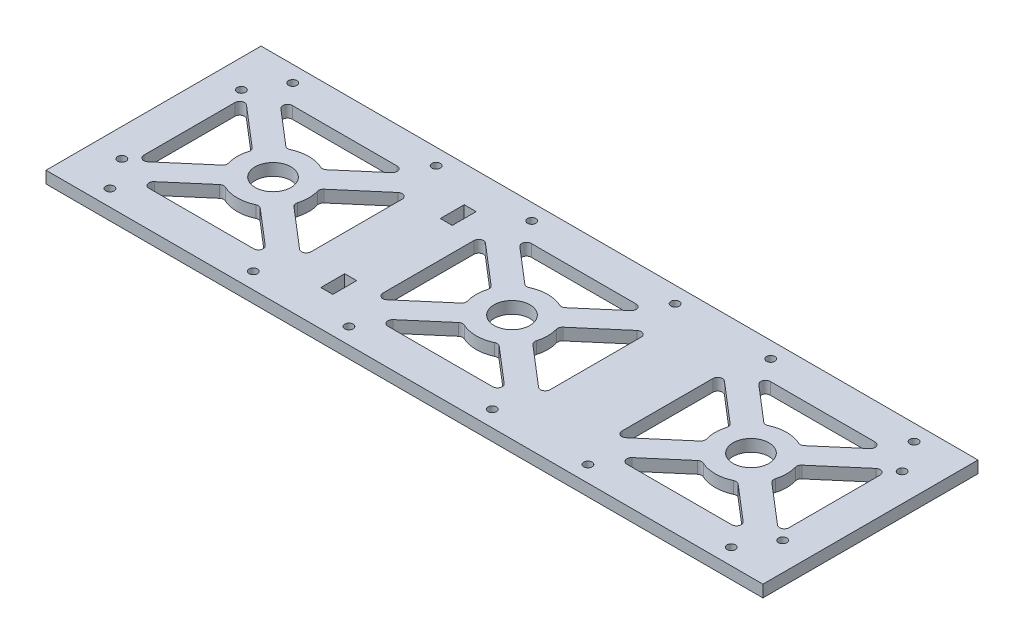
from build123d import *

# Parameters (mm, degrees)
SKETCH1_R           = 7.5
SKETCH1_R_2         = 1.75
SKETCH1_W           = 5
SKETCH1_H           = 10
BOSS_EXTRUDE2_DEPTH = 5


with BuildPart() as part:
    # Sketch1 → Boss-Extrude2 (new body)
    with BuildSketch(Plane(origin=(0, 0, 0), x_dir=(1, 0, 0), z_dir=(0, 1, 0))):
        Polygon((-50, 45), (150, 45), (150, -45), (-50, -45), (-150, -45), (-150, 45), align=None)
        Circle(SKETCH1_R, mode=Mode.SUBTRACT)
        with Locations((100, 0)):
            Circle(SKETCH1_R, mode=Mode.SUBTRACT)
        with Locations((-100, 0)):
            Circle(SKETCH1_R, mode=Mode.SUBTRACT)
        with Locations((-138.25, 25)):
            Circle(SKETCH1_R_2, mode=Mode.SUBTRACT)
        with Locations((-130, 38.25)):
            Circle(SKETCH1_R_2, mode=Mode.SUBTRACT)
        with Locations((-138.25, -25)):
            Circle(SKETCH1_R_2, mode=Mode.SUBTRACT)
        with Locations((-70, 38.25)):
            Circle(SKETCH1_R_2, mode=Mode.SUBTRACT)
        with Locations((-30, 38.25)):
            Circle(SKETCH1_R_2, mode=Mode.SUBTRACT)
        with Locations((30, 38.25)):
            Circle(SKETCH1_R_2, mode=Mode.SUBTRACT)
        with Locations((70, 38.25)):
            Circle(SKETCH1_R_2, mode=Mode.SUBTRACT)
        with Locations((130, 38.25)):
            Circle(SKETCH1_R_2, mode=Mode.SUBTRACT)
        with Locations((-130, -38.25)):
            Circle(SKETCH1_R_2, mode=Mode.SUBTRACT)
        with Locations((-70, -38.25)):
            Circle(SKETCH1_R_2, mode=Mode.SUBTRACT)
        with Locations((-30, -38.25)):
            Circle(SKETCH1_R_2, mode=Mode.SUBTRACT)
        with Locations((30, -38.25)):
            Circle(SKETCH1_R_2, mode=Mode.SUBTRACT)
        with Locations((70, -38.25)):
            Circle(SKETCH1_R_2, mode=Mode.SUBTRACT)
        with Locations((130, -38.25)):
            Circle(SKETCH1_R_2, mode=Mode.SUBTRACT)
        with Locations((138.25, -25)):
            Circle(SKETCH1_R_2, mode=Mode.SUBTRACT)
        with Locations((138.25, 25)):
            Circle(SKETCH1_R_2, mode=Mode.SUBTRACT)
        with BuildLine():
            Line((-21.910531466, 30), (21.910531466, 30))
            ThreePointArc((21.910531466, 30), (23.786301496, 28.693892495), (23.212114213, 26.481486795))
            Line((23.212114213, 26.481486795), (8.508395839, 13.878299617))
            ThreePointArc((8.508395839, 13.878299617), (7.476831919, 13.41512419), (6.358952728, 13.585423078))
            ThreePointArc((6.358952728, 13.585423078), (0, 15), (-6.358952728, 13.585423078))
            ThreePointArc((-6.358952728, 13.585423078), (-7.476831919, 13.41512419), (-8.508395839, 13.878299617))
            Line((-8.508395839, 13.878299617), (-23.212114213, 26.481486795))
            ThreePointArc((-23.212114213, 26.481486795), (-23.786301496, 28.693892495), (-21.910531466, 30))
        make_face(mode=Mode.SUBTRACT)
        with BuildLine():
            Line((-35, 19.066169828), (-35, -19.066169828))
            ThreePointArc((-35, -19.066169828), (-33.835713619, -20.883195625), (-31.698417253, -20.584683033))
            Line((-31.698417253, -20.584683033), (-15.016309573, -6.285733593))
            ThreePointArc((-15.016309573, -6.285733593), (-14.400814669, -5.337144314), (-14.398140282, -4.206370931))
            ThreePointArc((-14.398140282, -4.206370931), (-15, 0), (-14.398140282, 4.206370931))
            ThreePointArc((-14.398140282, 4.206370931), (-14.400814669, 5.337144314), (-15.016309573, 6.285733593))
            Line((-15.016309573, 6.285733593), (-31.698417253, 20.584683033))
            ThreePointArc((-31.698417253, 20.584683033), (-33.835713619, 20.883195625), (-35, 19.066169828))
        make_face(mode=Mode.SUBTRACT)
        with BuildLine():
            Line((-21.910531466, -30), (21.910531466, -30))
            ThreePointArc((21.910531466, -30), (23.786301496, -28.693892495), (23.212114213, -26.481486795))
            Line((23.212114213, -26.481486795), (8.508395839, -13.878299617))
            ThreePointArc((8.508395839, -13.878299617), (7.476831919, -13.41512419), (6.358952728, -13.585423078))
            ThreePointArc((6.358952728, -13.585423078), (0, -15), (-6.358952728, -13.585423078))
            ThreePointArc((-6.358952728, -13.585423078), (-7.476831919, -13.41512419), (-8.508395839, -13.878299617))
            Line((-8.508395839, -13.878299617), (-23.212114213, -26.481486795))
            ThreePointArc((-23.212114213, -26.481486795), (-23.786301496, -28.693892495), (-21.910531466, -30))
        make_face(mode=Mode.SUBTRACT)
        with BuildLine():
            Line((35, 19.066169828), (35, -19.066169828))
            ThreePointArc((35, -19.066169828), (33.835713619, -20.883195625), (31.698417253, -20.584683033))
            Line((31.698417253, -20.584683033), (15.016309573, -6.285733593))
            ThreePointArc((15.016309573, -6.285733593), (14.400814669, -5.337144314), (14.398140282, -4.206370931))
            ThreePointArc((14.398140282, -4.206370931), (15, 0), (14.398140282, 4.206370931))
            ThreePointArc((14.398140282, 4.206370931), (14.400814669, 5.337144314), (15.016309573, 6.285733593))
            Line((15.016309573, 6.285733593), (31.698417253, 20.584683033))
            ThreePointArc((31.698417253, 20.584683033), (33.835713619, 20.883195625), (35, 19.066169828))
        make_face(mode=Mode.SUBTRACT)
        with BuildLine():
            Line((131.698417253, -20.584683033), (115.016309573, -6.285733593))
            ThreePointArc((115.016309573, -6.285733593), (114.400814669, -5.337144314), (114.398140282, -4.206370931))
            ThreePointArc((114.398140282, -4.206370931), (115, 0), (114.398140282, 4.206370931))
            ThreePointArc((114.398140282, 4.206370931), (114.400814669, 5.337144314), (115.016309573, 6.285733593))
            Line((115.016309573, 6.285733593), (131.698417253, 20.584683033))
            ThreePointArc((131.698417253, 20.584683033), (133.835713619, 20.883195625), (135, 19.066169828))
            Line((135, 19.066169828), (135, -19.066169828))
            ThreePointArc((135, -19.066169828), (133.835713619, -20.883195625), (131.698417253, -20.584683033))
        make_face(mode=Mode.SUBTRACT)
        with BuildLine():
            Line((123.212114213, -26.481486795), (108.508395839, -13.878299617))
            ThreePointArc((108.508395839, -13.878299617), (107.476831919, -13.41512419), (106.358952728, -13.585423078))
            ThreePointArc((106.358952728, -13.585423078), (100, -15), (93.641047272, -13.585423078))
            ThreePointArc((93.641047272, -13.585423078), (92.523168081, -13.41512419), (91.491604161, -13.878299617))
            Line((91.491604161, -13.878299617), (76.787885787, -26.481486795))
            ThreePointArc((76.787885787, -26.481486795), (76.213698504, -28.693892495), (78.089468534, -30))
            Line((78.089468534, -30), (121.910531466, -30))
            ThreePointArc((121.910531466, -30), (123.786301496, -28.693892495), (123.212114213, -26.481486795))
        make_face(mode=Mode.SUBTRACT)
        with BuildLine():
            Line((68.301582747, -20.584683033), (84.983690427, -6.285733593))
            ThreePointArc((84.983690427, -6.285733593), (85.599185331, -5.337144314), (85.601859718, -4.206370931))
            ThreePointArc((85.601859718, -4.206370931), (85, 0), (85.601859718, 4.206370931))
            ThreePointArc((85.601859718, 4.206370931), (85.599185331, 5.337144314), (84.983690427, 6.285733593))
            Line((84.983690427, 6.285733593), (68.301582747, 20.584683033))
            ThreePointArc((68.301582747, 20.584683033), (66.164286381, 20.883195625), (65, 19.066169828))
            Line((65, 19.066169828), (65, -19.066169828))
            ThreePointArc((65, -19.066169828), (66.164286381, -20.883195625), (68.301582747, -20.584683033))
        make_face(mode=Mode.SUBTRACT)
        with BuildLine():
            Line((76.787885787, 26.481486795), (91.491604161, 13.878299617))
            ThreePointArc((91.491604161, 13.878299617), (92.523168081, 13.41512419), (93.641047272, 13.585423078))
            ThreePointArc((93.641047272, 13.585423078), (100, 15), (106.358952728, 13.585423078))
            ThreePointArc((106.358952728, 13.585423078), (107.476831919, 13.41512419), (108.508395839, 13.878299617))
            Line((108.508395839, 13.878299617), (123.212114213, 26.481486795))
            ThreePointArc((123.212114213, 26.481486795), (123.786301496, 28.693892495), (121.910531466, 30))
            Line((121.910531466, 30), (78.089468534, 30))
            ThreePointArc((78.089468534, 30), (76.213698504, 28.693892495), (76.787885787, 26.481486795))
        make_face(mode=Mode.SUBTRACT)
        with BuildLine():
            Line((-68.301582747, -20.584683033), (-84.983690427, -6.285733593))
            ThreePointArc((-84.983690427, -6.285733593), (-85.599185331, -5.337144314), (-85.601859718, -4.206370931))
            ThreePointArc((-85.601859718, -4.206370931), (-85, 0), (-85.601859718, 4.206370931))
            ThreePointArc((-85.601859718, 4.206370931), (-85.599185331, 5.337144314), (-84.983690427, 6.285733593))
            Line((-84.983690427, 6.285733593), (-68.301582747, 20.584683033))
            ThreePointArc((-68.301582747, 20.584683033), (-66.164286381, 20.883195625), (-65, 19.066169828))
            Line((-65, 19.066169828), (-65, -19.066169828))
            ThreePointArc((-65, -19.066169828), (-66.164286381, -20.883195625), (-68.301582747, -20.584683033))
        make_face(mode=Mode.SUBTRACT)
        with BuildLine():
            Line((-76.787885787, -26.481486795), (-91.491604161, -13.878299617))
            ThreePointArc((-91.491604161, -13.878299617), (-92.523168081, -13.41512419), (-93.641047272, -13.585423078))
            ThreePointArc((-93.641047272, -13.585423078), (-100, -15), (-106.358952728, -13.585423078))
            ThreePointArc((-106.358952728, -13.585423078), (-107.476831919, -13.41512419), (-108.508395839, -13.878299617))
            Line((-108.508395839, -13.878299617), (-123.212114213, -26.481486795))
            ThreePointArc((-123.212114213, -26.481486795), (-123.786301496, -28.693892495), (-121.910531466, -30))
            Line((-121.910531466, -30), (-78.089468534, -30))
            ThreePointArc((-78.089468534, -30), (-76.213698504, -28.693892495), (-76.787885787, -26.481486795))
        make_face(mode=Mode.SUBTRACT)
        with BuildLine():
            Line((-131.698417253, -20.584683033), (-115.016309573, -6.285733593))
            ThreePointArc((-115.016309573, -6.285733593), (-114.400814669, -5.337144314), (-114.398140282, -4.206370931))
            ThreePointArc((-114.398140282, -4.206370931), (-115, 0), (-114.398140282, 4.206370931))
            ThreePointArc((-114.398140282, 4.206370931), (-114.400814669, 5.337144314), (-115.016309573, 6.285733593))
            Line((-115.016309573, 6.285733593), (-131.698417253, 20.584683033))
            ThreePointArc((-131.698417253, 20.584683033), (-133.835713619, 20.883195625), (-135, 19.066169828))
            Line((-135, 19.066169828), (-135, -19.066169828))
            ThreePointArc((-135, -19.066169828), (-133.835713619, -20.883195625), (-131.698417253, -20.584683033))
        make_face(mode=Mode.SUBTRACT)
        with BuildLine():
            Line((-123.212114213, 26.481486795), (-108.508395839, 13.878299617))
            ThreePointArc((-108.508395839, 13.878299617), (-107.476831919, 13.41512419), (-106.358952728, 13.585423078))
            ThreePointArc((-106.358952728, 13.585423078), (-100, 15), (-93.641047272, 13.585423078))
            ThreePointArc((-93.641047272, 13.585423078), (-92.523168081, 13.41512419), (-91.491604161, 13.878299617))
            Line((-91.491604161, 13.878299617), (-76.787885787, 26.481486795))
            ThreePointArc((-76.787885787, 26.481486795), (-76.213698504, 28.693892495), (-78.089468534, 30))
            Line((-78.089468534, 30), (-121.910531466, 30))
            ThreePointArc((-121.910531466, 30), (-123.786301496, 28.693892495), (-123.212114213, 26.481486795))
        make_face(mode=Mode.SUBTRACT)
        with Locations((-47.5, 25)):
            Rectangle(SKETCH1_W, SKETCH1_H, mode=Mode.SUBTRACT)
        with Locations((-47.5, -25)):
            Rectangle(SKETCH1_W, SKETCH1_H, mode=Mode.SUBTRACT)
    extrude(amount=BOSS_EXTRUDE2_DEPTH)


solid = part.part
